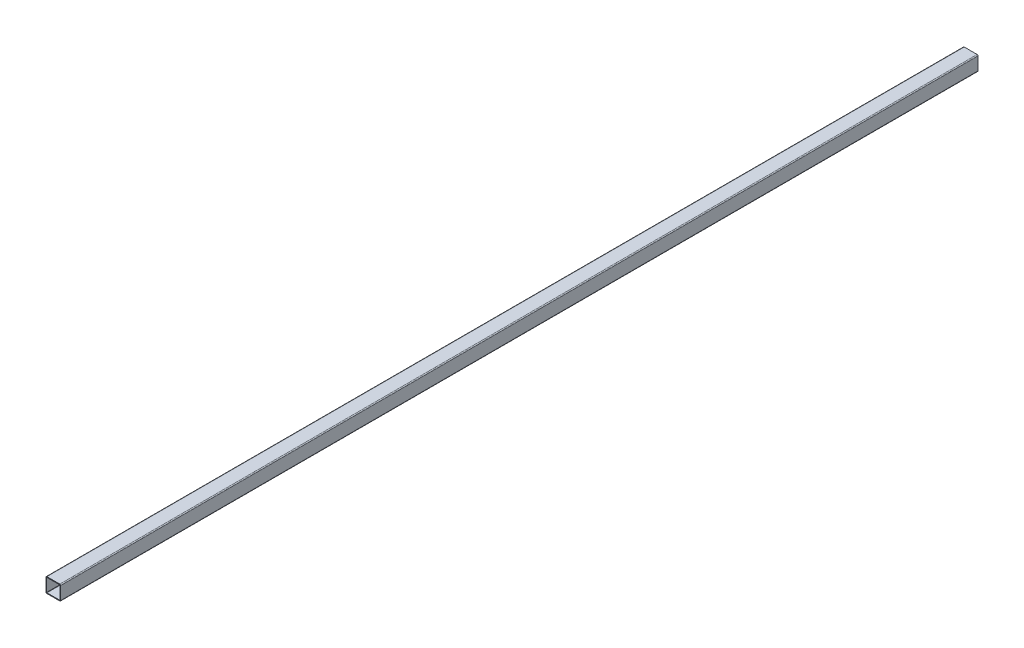
from build123d import *

# Parameters (mm, degrees)
BOSS_EXTRUDE1_DEPTH      = 1000
BOSS_EXTRUDE1_DEPTH_BACK = 1000


with BuildPart() as part:
    # Sketch1 → Boss-Extrude1 (new, two sides: drawn at the far end of the back side and taken through both)
    with BuildSketch(Plane.XY.offset(-BOSS_EXTRUDE1_DEPTH_BACK)):
        with BuildLine():
            Line((-14, -16), (14, -16))
            ThreePointArc((14, -16), (15.414213562, -15.414213562), (16, -14))
            Line((16, -14), (16, 14))
            ThreePointArc((16, 14), (15.414213562, 15.414213562), (14, 16))
            Line((14, 16), (-14, 16))
            ThreePointArc((-14, 16), (-15.414213562, 15.414213562), (-16, 14))
            Line((-16, 14), (-16, -14))
            ThreePointArc((-16, -14), (-15.414213562, -15.414213562), (-14, -16))
        make_face()
        with BuildLine():
            Line((-14, 14.48), (14, 14.48))
            ThreePointArc((14, 14.48), (14.339411255, 14.339411255), (14.48, 14))
            Line((14.48, 14), (14.48, -14))
            ThreePointArc((14.48, -14), (14.339411255, -14.339411255), (14, -14.48))
            Line((14, -14.48), (-14, -14.48))
            ThreePointArc((-14, -14.48), (-14.339411255, -14.339411255), (-14.48, -14))
            Line((-14.48, -14), (-14.48, 14))
            ThreePointArc((-14.48, 14), (-14.339411255, 14.339411255), (-14, 14.48))
        make_face(mode=Mode.SUBTRACT)
    extrude(amount=BOSS_EXTRUDE1_DEPTH + BOSS_EXTRUDE1_DEPTH_BACK)


solid = part.part
